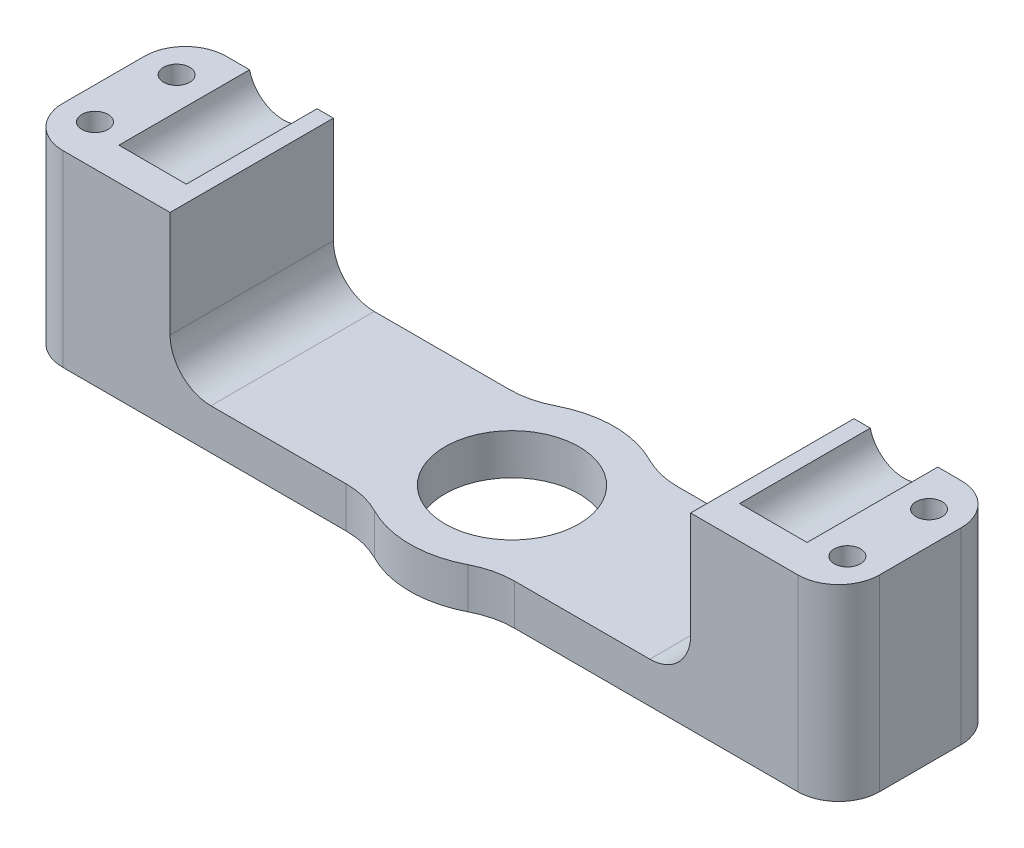
from build123d import *

# Parameters (mm, degrees)
SKETCH1_W               = 88
SKETCH1_H               = 20
BOSS_EXTRUDE1_DEPTH     = 48
SKETCH2_R               = 4.25
CUT_EXTRUDE1_DEPTH      = 21
SKETCH7_R               = 12.5
BOSS_EXTRUDE2_DEPTH     = 48
SKETCH4_R               = 8.2
CUT_EXTRUDE3_DEPTH      = 49
FILLET2_R               = 10
SKETCH9_W               = 27
SKETCH9_H               = 25
CUT_EXTRUDE4_DEPTH      = 89
SKETCH10_W              = 63.73864418
SKETCH10_H              = 20
CUT_EXTRUDE5_DEPTH      = 13.5
CUT_EXTRUDE5_DEPTH_BACK = 13.5
FILLET3_R               = 5
SKETCH11_W              = 20
SKETCH11_H              = 23
BOSS_EXTRUDE3_DEPTH     = 6
SKETCH12_R              = 1.6
CUT_EXTRUDE6_DEPTH      = 24
FILLET5_R               = 5
BOSS_EXTRUDE4_DEPTH     = 4


with BuildPart() as part:
    # Sketch1 → Boss-Extrude1 (new body)
    with BuildSketch(Plane(origin=(0, 0, 0), x_dir=(1, 0, 0), z_dir=(0, 1, 0))):
        Rectangle(SKETCH1_W, SKETCH1_H)
    extrude(amount=BOSS_EXTRUDE1_DEPTH)

    # Sketch2 → Cut-Extrude1 (cut, through all)
    with BuildSketch(Plane.XY.offset(10)):
        with Locations((-38, 24)):
            Circle(SKETCH2_R)
        with Locations((38, 24)):
            Circle(SKETCH2_R)
    extrude(amount=-CUT_EXTRUDE1_DEPTH, mode=Mode.SUBTRACT)

    # Sketch7 → Boss-Extrude2 (add)
    with BuildSketch(Plane(origin=(0, 48, 0), x_dir=(1, 0, 0), z_dir=(0, 1, 0))):
        Circle(SKETCH7_R)
    extrude(amount=-BOSS_EXTRUDE2_DEPTH)

    # Sketch4 → Cut-Extrude3 (cut, through all)
    with BuildSketch(Plane(origin=(0, 48, 0), x_dir=(1, 0, 0), z_dir=(0, 1, 0))):
        Circle(SKETCH4_R)
    extrude(amount=-CUT_EXTRUDE3_DEPTH, mode=Mode.SUBTRACT)

    # Fillet2
    fillet2_edges = [part.edges().sort_by_distance(p)[0] for p in [
        (7.5, 24, -10),
        (7.5, 24, 10),
        (-7.5, 24, -10),
        (-7.5, 24, 10),
    ]]
    fillet(fillet2_edges, radius=FILLET2_R)

    # Sketch9 → Cut-Extrude4 (cut, through all)
    with BuildSketch(Plane.ZY.offset(44)):
        with Locations((0, 35.5)):
            Rectangle(SKETCH9_W, SKETCH9_H)
    extrude(amount=-CUT_EXTRUDE4_DEPTH, mode=Mode.SUBTRACT)

    # Sketch10 → Cut-Extrude5 (cut, two sides)
    with BuildSketch(Plane.XY) as cut_extrude5_sk:
        with Locations((0, 15)):
            Rectangle(SKETCH10_W, SKETCH10_H)
    extrude(amount=CUT_EXTRUDE5_DEPTH, mode=Mode.SUBTRACT)
    extrude(cut_extrude5_sk.sketch, amount=-CUT_EXTRUDE5_DEPTH_BACK, mode=Mode.SUBTRACT)

    # Fillet3
    fillet3_edges = [part.edges().sort_by_distance(p)[0] for p in [
        (31.86932209, 5, 0),
        (-31.86932209, 5, 0),
    ]]
    fillet(fillet3_edges, radius=FILLET3_R)

    # Sketch11 → Boss-Extrude3 (add)
    with BuildSketch(Plane(origin=(44, 0, 0), x_dir=(0, 0, -1), z_dir=(1, 0, 0))):
        with Locations((0, 11.5)):
            Rectangle(SKETCH11_W, SKETCH11_H)
    boss_extrude3 = extrude(amount=BOSS_EXTRUDE3_DEPTH)

    # Sketch12 → Cut-Extrude6 (cut, through all)
    with BuildSketch(Plane(origin=(0, 23, 0), x_dir=(1, 0, 0), z_dir=(0, 1, 0))):
        with Locations((46.065338955, 5)):
            Circle(SKETCH12_R)
        with Locations((46.065338955, -5)):
            Circle(SKETCH12_R)
    cut_extrude6 = extrude(amount=-CUT_EXTRUDE6_DEPTH, mode=Mode.SUBTRACT)

    # Mirror1: Boss-Extrude3, Cut-Extrude6 across plane
    add(boss_extrude3.mirror(Plane(origin=(0, 0, 0), x_dir=(0, 0, 1), z_dir=(1, 0, 0))))
    add(cut_extrude6.mirror(Plane(origin=(0, 0, 0), x_dir=(0, 0, 1), z_dir=(1, 0, 0))), mode=Mode.SUBTRACT)

    # Fillet5
    fillet5_edges = [part.edges().sort_by_distance(p)[0] for p in [
        (50, 11.5, -10),
        (50, 11.5, 10),
        (-50, 11.5, 10),
        (-50, 11.5, -10),
    ]]
    fillet(fillet5_edges, radius=FILLET5_R)

    # Sketch13 → Boss-Extrude4 (add)
    with BuildSketch(Plane.XY.offset(10)):
        with BuildLine():
            Line((-42.13067791, 23), (-33.86932209, 23))
            ThreePointArc((-33.86932209, 23), (-38, 19.75), (-42.13067791, 23))
        make_face()
        with BuildLine():
            Line((33.86932209, 23), (42.13067791, 23))
            ThreePointArc((42.13067791, 23), (38, 19.75), (33.86932209, 23))
        make_face()
    extrude(amount=-BOSS_EXTRUDE4_DEPTH)


solid = part.part
